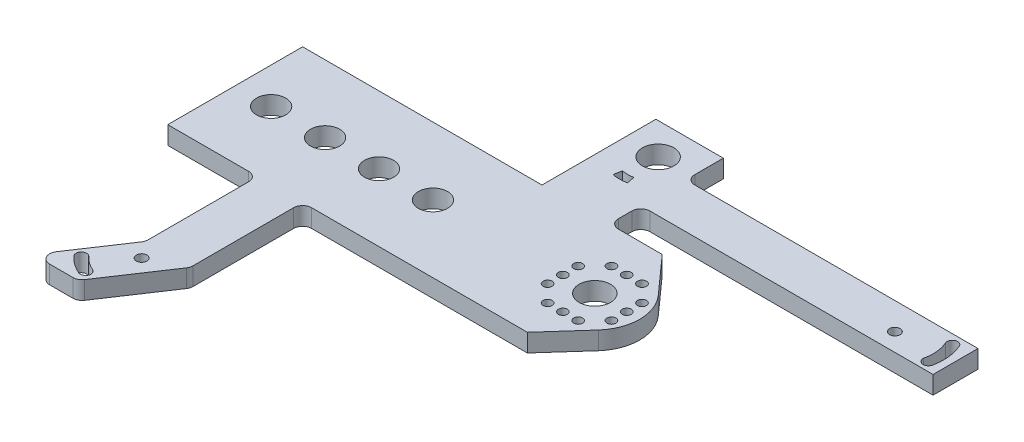
from build123d import *

# Parameters (mm, degrees)
SKETCH1_R           = 10
BOSS_EXTRUDE1_DEPTH = 4
SKETCH2_W           = 80
SKETCH2_H           = 30
BOSS_EXTRUDE2_DEPTH = 4
SKETCH5_W           = 15
SKETCH5_H           = 25.341978046
SKETCH5_R           = 3.5
BOSS_EXTRUDE3_DEPTH = 4
CUT_EXTRUDE1_DEPTH  = 5
SKETCH7_R           = 3.25
CUT_EXTRUDE2_DEPTH  = 5
LPATTERN1_COUNT     = 4
LPATTERN1_PITCH     = 12
SKETCH8_W           = 65
SKETCH8_H           = 10
BOSS_EXTRUDE4_DEPTH = 4
SKETCH9_R           = 1.175
CUT_EXTRUDE3_DEPTH  = 4
SKETCH10_W          = 10
SKETCH10_H          = 25
BOSS_EXTRUDE5_DEPTH = 4
SKETCH11_R          = 1.175
CUT_EXTRUDE4_DEPTH  = 4
SKETCH12_R          = 1
CUT_EXTRUDE5_DEPTH  = 5
CIRPATTERN1_COUNT   = 4
SKETCH13_R          = 3.5
CUT_EXTRUDE6_DEPTH  = 5
FILLET1_R           = 2


with BuildPart() as part:
    # Sketch1 → Boss-Extrude1 (new body)
    with BuildSketch(Plane(origin=(0, 0, 0), x_dir=(1, 0, 0), z_dir=(0, 1, 0))):
        Circle(SKETCH1_R)
    extrude(amount=BOSS_EXTRUDE1_DEPTH)

    # Sketch2 → Boss-Extrude2 (add)
    with BuildSketch(Plane(origin=(0, 0, 0), x_dir=(1, 0, 0), z_dir=(0, 1, 0))):
        with Locations((-40, 0)):
            Rectangle(SKETCH2_W, SKETCH2_H)
        Polygon((7.453553273, 6.666674104), (7.453553273, -6.666674104), (0, -15), (0, 15), align=None)
    extrude(amount=BOSS_EXTRUDE2_DEPTH)

    # Sketch5 → Boss-Extrude3 (add)
    with BuildSketch(Plane(origin=(0, 0, 0), x_dir=(1, 0, 0), z_dir=(0, 1, 0))):
        with Locations((-19.25, 27.670989023)):
            Rectangle(SKETCH5_W, SKETCH5_H)
        with Locations((-19.25, 33.341978046)):
            Circle(SKETCH5_R, mode=Mode.SUBTRACT)
    extrude(amount=BOSS_EXTRUDE3_DEPTH)

    # Sketch6 → Cut-Extrude1 (cut, through all)
    with BuildSketch(Plane(origin=(0, 4, 0), x_dir=(1, 0, 0), z_dir=(0, 1, 0))):
        with BuildLine():
            Line((-20.85, 24.912482213), (-20.514335664, 26.680907912))
            ThreePointArc((-20.514335664, 26.680907912), (-19.88495846, 26.591775993), (-19.25, 26.561978046))
            Line((-19.25, 26.561978046), (-19.25, 24.761978046))
            ThreePointArc((-19.25, 24.761978046), (-20.053531503, 24.799686952), (-20.85, 24.912482213))
        make_face()
    cut_extrude1 = extrude(amount=-CUT_EXTRUDE1_DEPTH, mode=Mode.SUBTRACT)

    # Mirror1: Cut-Extrude1 across plane
    add(cut_extrude1.mirror(Plane.ZY.offset(19.25)), mode=Mode.SUBTRACT)

    # Sketch7 → Cut-Extrude2 (cut, through all)
    with BuildSketch(Plane(origin=(0, 4, 0), x_dir=(1, 0, 0), z_dir=(0, 1, 0))):
        with Locations((-72, 0)):
            Circle(SKETCH7_R)
    cut_extrude2 = extrude(amount=-CUT_EXTRUDE2_DEPTH, mode=Mode.SUBTRACT)

    # LPattern1: Cut-Extrude2 ×4
    with Locations(*[(i * LPATTERN1_PITCH, 0, 0) for i in range(1, LPATTERN1_COUNT)]):
        add(cut_extrude2, mode=Mode.SUBTRACT)

    # Sketch8 → Boss-Extrude4 (add)
    with BuildSketch(Plane(origin=(0, 0, 0), x_dir=(1, 0, 0), z_dir=(0, 1, 0))):
        with Locations((20.75, 27)):
            Rectangle(SKETCH8_W, SKETCH8_H)
    extrude(amount=BOSS_EXTRUDE4_DEPTH)

    # Sketch9 → Cut-Extrude3 (cut)
    with BuildSketch(Plane(origin=(0, 4, 0), x_dir=(1, 0, 0), z_dir=(0, 1, 0))):
        with Locations((40.75, 26)):
            Circle(SKETCH9_R)
        with BuildLine():
            ThreePointArc((50.718101372, 30.374564563), (51.56619893, 27.22869882), (51.445333625, 23.97276081))
            ThreePointArc((51.445333625, 23.97276081), (50.22276081, 22.804666375), (49.054666375, 24.02723919))
            ThreePointArc((49.054666375, 24.02723919), (49.251093716, 26.76855347), (48.566204822, 29.430191102))
            ThreePointArc((48.566204822, 29.430191102), (49.169966366, 30.978326108), (50.718101372, 30.374564563))
        make_face()
    extrude(amount=-CUT_EXTRUDE3_DEPTH, mode=Mode.SUBTRACT)

    # Sketch10 → Boss-Extrude5 (add)
    with BuildSketch(Plane(origin=(0, 0, 0), x_dir=(1, 0, 0), z_dir=(0, 1, 0))):
        Polygon((-60, -55), (-60, -40), (-50, -40), align=None)
        with Locations((-55, -27.5)):
            Rectangle(SKETCH10_W, SKETCH10_H)
        Polygon((-60, -40), (-70, -55), (-60, -55), align=None)
    extrude(amount=BOSS_EXTRUDE5_DEPTH)

    # Sketch11 → Cut-Extrude4 (cut)
    with BuildSketch(Plane(origin=(0, 4, 0), x_dir=(1, 0, 0), z_dir=(0, 1, 0))):
        with Locations((-57.211102551, -43.605551275)):
            Circle(SKETCH11_R)
        with BuildLine():
            ThreePointArc((-61.363573117, -53.4398084), (-63.3936658, -52.307938113), (-65.130655612, -50.763505195))
            ThreePointArc((-65.130655612, -50.763505195), (-65.046826198, -49.103920117), (-63.387241121, -49.187749531))
            ThreePointArc((-63.387241121, -49.187749531), (-62.032633141, -50.392190191), (-60.449446107, -51.27488997))
            ThreePointArc((-60.449446107, -51.27488997), (-59.824050397, -52.81441269), (-61.363573117, -53.4398084))
        make_face()
    extrude(amount=-CUT_EXTRUDE4_DEPTH, mode=Mode.SUBTRACT)

    # Sketch12 → Cut-Extrude5 (cut, through all)
    with BuildSketch(Plane(origin=(0, 4, 0), x_dir=(1, 0, 0), z_dir=(0, 1, 0))):
        with Locations((7.1, 3.4)):
            Circle(SKETCH12_R)
        with Locations((7.1, -3.4)):
            Circle(SKETCH12_R)
        with Locations((7.1, 0)):
            Circle(SKETCH12_R)
    cut_extrude5 = extrude(amount=-CUT_EXTRUDE5_DEPTH, mode=Mode.SUBTRACT)

    # CirPattern1: Cut-Extrude5 ×4 about axis
    cirpattern1_axis = Axis((0, 0, 0), (0, 1, 0))
    for i in range(1, CIRPATTERN1_COUNT):
        add(cut_extrude5.rotate(cirpattern1_axis, i * 360 / CIRPATTERN1_COUNT), mode=Mode.SUBTRACT)

    # Sketch13 → Cut-Extrude6 (cut, through all)
    with BuildSketch(Plane(origin=(0, 4, 0), x_dir=(1, 0, 0), z_dir=(0, 1, 0))):
        Circle(SKETCH13_R)
    extrude(amount=-CUT_EXTRUDE6_DEPTH, mode=Mode.SUBTRACT)

    # Fillet1
    fillet1_edges = [part.edges().sort_by_distance(p)[0] for p in [
        (-11.75, 2, -32),
        (-11.75, 2, -22),
        (-60, 2, 15),
        (-60, 2, 40),
        (-70, 2, 55),
        (-60, 2, 55),
        (-50, 2, 40),
        (-50, 2, 15),
        (-11.75, 2, -15),
    ]]
    fillet(fillet1_edges, radius=FILLET1_R)


solid = part.part
